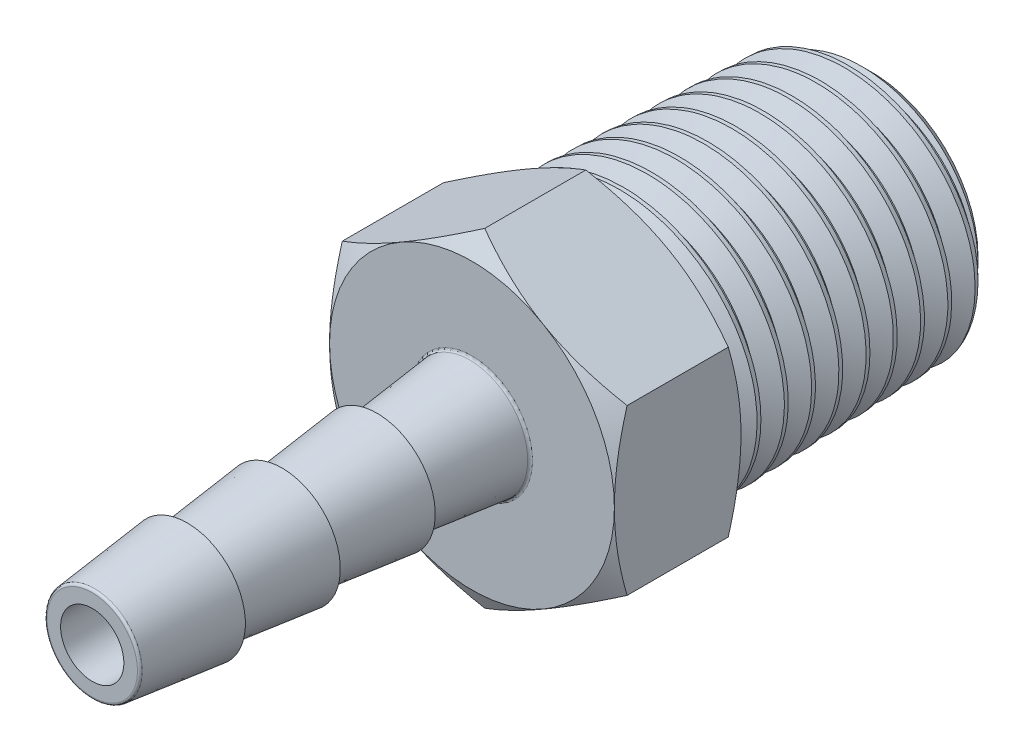
from build123d import *

# Parameters (mm, degrees)
LPATTERN1_COUNT        = 3
LPATTERN1_PITCH        = 4.7625
SKETCH4_R              = 6.38777167
BOSS_EXTRUDE1_DEPTH    = 13.716
BOSS_EXTRUDE1_DRAFT    = -1.78333333
CUT_SWEEP1_PITCH       = 1.411794907
CUT_SWEEP1_HEIGHT      = 15.127111111
CUT_SWEEP1_RADIUS      = 6.38777167
CUT_SWEEP1_START_ANGLE = 90
SKETCH7_OUTSIDE_W      = 51.726
SKETCH7_OUTSIDE_H      = 51.748
SKETCH7_OUTSIDE_R      = 5.318470859
CUT_EXTRUDE1_DEPTH     = 13.716
CUT_EXTRUDE1_DRAFT     = -45
BOSS_EXTRUDE2_DEPTH    = 6.35
SKETCH9_OUTSIDE_W      = 107.834
SKETCH9_OUTSIDE_H      = 110.044
SKETCH9_OUTSIDE_R      = 7.14375
CUT_EXTRUDE2_DEPTH     = 23.84122908
CUT_EXTRUDE2_DRAFT     = -60
SKETCH10_OUTSIDE_W     = 124.476
SKETCH10_OUTSIDE_H     = 126.686
SKETCH10_OUTSIDE_R     = 7.14375
CUT_EXTRUDE3_DEPTH     = 28.644843749
CUT_EXTRUDE3_DRAFT     = -60
SKETCH11_W             = 24.01316
SKETCH11_H             = 1.5875
CHAMFER1_SIZE          = 0.635
CHAMFER1_SIZE2         = 0.366617421
FILLET1_R              = 0.127


with BuildPart() as part:
    # Sketch2 → Revolve1 (revolve)
    with BuildSketch(Plane(origin=(0, 0, 0), x_dir=(0, 0, -1), z_dir=(1, 0, 0)), mode=Mode.PRIVATE) as revolve1_sk:
        Polygon((-19.05, 2.38125), (-4.7625, 2.38125), (0, 2.921), (0, 0), (-19.05, 0), align=None)
    revolve(revolve1_sk.sketch.rotate(Axis((0, 0, 19.05), (0, 0, -1)), 180), axis=Axis((0, 0, 19.05), (0, 0, -1)))

    # Sketch3 → Revolve2 (revolve)
    with BuildSketch(Plane(origin=(0, 0, 0), x_dir=(0, 0, -1), z_dir=(1, 0, 0)), mode=Mode.PRIVATE) as revolve2_sk:
        Polygon((-19.05, 2.38125), (-14.2875, 2.921), (-14.2875, 2.38125), align=None)
    revolve2 = revolve(revolve2_sk.sketch.rotate(Axis((0, 0, 0), (0, 0, 1)), 180), axis=Axis((0, 0, 0), (0, 0, 1)))

    # LPattern1: Revolve2 ×3
    with Locations(*[(0, 0, -i * LPATTERN1_PITCH) for i in range(1, LPATTERN1_COUNT)]):
        add(revolve2)



with BuildPart() as body_2:
    # Sketch4 → Boss-Extrude1 (with draft: the straight prism first)
    with BuildSketch(Plane.XY.offset(-20.066)):
        Circle(SKETCH4_R)
    extrude(amount=BOSS_EXTRUDE1_DEPTH)
    # Boss-Extrude1: the draft: its side faces are tilted about the plane it starts from
    boss_extrude1_sides = [body_2.faces().sort_by_distance(p)[0] for p in [
        (-6.38777167, 0, -13.208),
    ]]
    draft(boss_extrude1_sides, Plane.XY.offset(-20.066), BOSS_EXTRUDE1_DRAFT)

    # Cut-Sweep1: sweep along a helix
    with BuildLine() as cut_sweep1_path:
        # a taper helix: rise per turn along the axis 1.411111111, along the cone's slant (build123d's pitch) 1.411794907
        add(Helix(CUT_SWEEP1_PITCH, CUT_SWEEP1_HEIGHT, CUT_SWEEP1_RADIUS, center=(0, 0, -20.066), direction=(0, 0, 1), cone_angle=1.78333333, mode=Mode.PRIVATE).rotate(Axis((0, 0, -20.066), (0, 0, 1)), CUT_SWEEP1_START_ANGLE))
    # Sketch6 → Cut-Sweep1 (sweep, cut)
    with BuildSketch(Plane(origin=(0, 0, 0), x_dir=(0, 0, -1), z_dir=(1, 0, 0))):
        Polygon((21.344819444, 6.464150299), (19.977805556, 6.540528929), (20.595166667, 5.471228117), (20.771555556, 5.471228117), align=None)
    sweep(path=cut_sweep1_path.line, is_frenet=True, mode=Mode.SUBTRACT)


with BuildPart() as cut_extrude1_tool:
    # Sketch7 outside → Cut-Extrude1 (with draft: the straight prism first)
    with BuildSketch(Plane(origin=(0, 0, -20.066), x_dir=(-1, 0, 0), z_dir=(0, 0, -1))):
        with Locations((0.011, -0.011)):
            Rectangle(SKETCH7_OUTSIDE_W, SKETCH7_OUTSIDE_H)
        Circle(SKETCH7_OUTSIDE_R, mode=Mode.SUBTRACT)
    extrude(amount=-CUT_EXTRUDE1_DEPTH)
    # Cut-Extrude1: the draft: its side faces are tilted about the plane it starts from
    cut_extrude1_sides = [cut_extrude1_tool.faces().sort_by_distance(p)[0] for p in [
        (-0.011, -25.885, -13.208),
        (-25.874, -0.011, -13.208),
        (-0.011, 25.863, -13.208),
        (25.852, -0.011, -13.208),
        (5.318470859, 0, -13.208),
    ]]
    draft(cut_extrude1_sides, Plane(origin=(0, 0, -20.066), x_dir=(-1, 0, 0), z_dir=(0, 0, -1)), CUT_EXTRUDE1_DRAFT)


with BuildPart() as body_2_1:
    add(body_2.part)

    # Cut-Extrude1: cut by cut_extrude1_tool
    add(cut_extrude1_tool.part, mode=Mode.SUBTRACT)


with BuildPart() as part_1:
    add(part.part)

    add(body_2_1.part)  # Boss-Extrude2 merges body 2
    # Sketch8 → Boss-Extrude2 (add)
    with BuildSketch(Plane(origin=(0, 0, 0), x_dir=(-1, 0, 0), z_dir=(0, 0, -1))):
        Polygon((0, 8.248891971), (-7.14375, 4.124445986), (-7.14375, -4.124445986), (0, -8.248891971), (7.14375, -4.124445986), (7.14375, 4.124445986), align=None)
    extrude(amount=BOSS_EXTRUDE2_DEPTH)


with BuildPart() as cut_extrude2_tool:
    # Sketch9 outside → Cut-Extrude2 (with draft: the straight prism first)
    with BuildSketch(Plane.XY):
        Rectangle(SKETCH9_OUTSIDE_W, SKETCH9_OUTSIDE_H)
        Circle(SKETCH9_OUTSIDE_R, mode=Mode.SUBTRACT)
    extrude(amount=-CUT_EXTRUDE2_DEPTH)
    # Cut-Extrude2: the draft: its side faces are tilted about the plane it starts from
    cut_extrude2_sides = [cut_extrude2_tool.faces().sort_by_distance(p)[0] for p in [
        (0, -55.022, -11.92061454),
        (53.917, 0, -11.92061454),
        (0, 55.022, -11.92061454),
        (-53.917, 0, -11.92061454),
        (-7.14375, 0, -11.92061454),
    ]]
    draft(cut_extrude2_sides, Plane.XY, CUT_EXTRUDE2_DRAFT)


with BuildPart() as part_2:
    add(part_1.part)

    # Cut-Extrude2: cut by cut_extrude2_tool
    add(cut_extrude2_tool.part, mode=Mode.SUBTRACT)


with BuildPart() as cut_extrude3_tool:
    # Sketch10 outside → Cut-Extrude3 (with draft: the straight prism first)
    with BuildSketch(Plane(origin=(0, 0, -6.35), x_dir=(-1, 0, 0), z_dir=(0, 0, -1))):
        Rectangle(SKETCH10_OUTSIDE_W, SKETCH10_OUTSIDE_H)
        Circle(SKETCH10_OUTSIDE_R, mode=Mode.SUBTRACT)
    extrude(amount=-CUT_EXTRUDE3_DEPTH)
    # Cut-Extrude3: the draft: its side faces are tilted about the plane it starts from
    cut_extrude3_sides = [cut_extrude3_tool.faces().sort_by_distance(p)[0] for p in [
        (0, -63.343, 7.972421874),
        (-62.238, 0, 7.972421874),
        (0, 63.343, 7.972421874),
        (62.238, 0, 7.972421874),
        (7.14375, 0, 7.972421874),
    ]]
    draft(cut_extrude3_sides, Plane(origin=(0, 0, -6.35), x_dir=(-1, 0, 0), z_dir=(0, 0, -1)), CUT_EXTRUDE3_DRAFT)


with BuildPart() as part_3:
    add(part_2.part)

    # Cut-Extrude3: cut by cut_extrude3_tool
    add(cut_extrude3_tool.part, mode=Mode.SUBTRACT)

    # Sketch11 → Cut-Revolve1 (revolve, cut)
    with BuildSketch(Plane(origin=(0, 0, 0), x_dir=(0, 0, -1), z_dir=(1, 0, 0))):
        with Locations((-7.04342, 0.79375)):
            Rectangle(SKETCH11_W, SKETCH11_H)
    revolve(axis=Axis((0, 0, 19.05), (0, 0, -1)), mode=Mode.SUBTRACT)

    # Sketch12 → Cut-Revolve3 (revolve, cut)
    with BuildSketch(Plane(origin=(0, 0, 0), x_dir=(0, 0, -1), z_dir=(1, 0, 0))):
        Polygon((20.066, 4.3561), (4.96316, 4.3561), (2.345751057, 0), (20.066, 0), align=None)
    revolve(axis=Axis((0, 0, 19.05), (0, 0, -1)), mode=Mode.SUBTRACT)

    # Chamfer1
    chamfer1_edges = [part_3.edges().sort_by_distance(p)[0] for p in [
        (0, -4.3561, -20.066),
    ]]
    chamfer1_side = [part_3.faces().sort_by_distance(p)[0] for p in [
        (0, -4.3561, -12.51458),
    ]]
    chamfer(chamfer1_edges, length=CHAMFER1_SIZE, length2=CHAMFER1_SIZE2, reference=chamfer1_side[0])

    # Fillet1
    fillet1_edges = [part_3.edges().sort_by_distance(p)[0] for p in [
        (0, 2.38125, 19.05),
        (0, 2.921, 0),
    ]]
    fillet(fillet1_edges, radius=FILLET1_R)


solid = part_3.part
